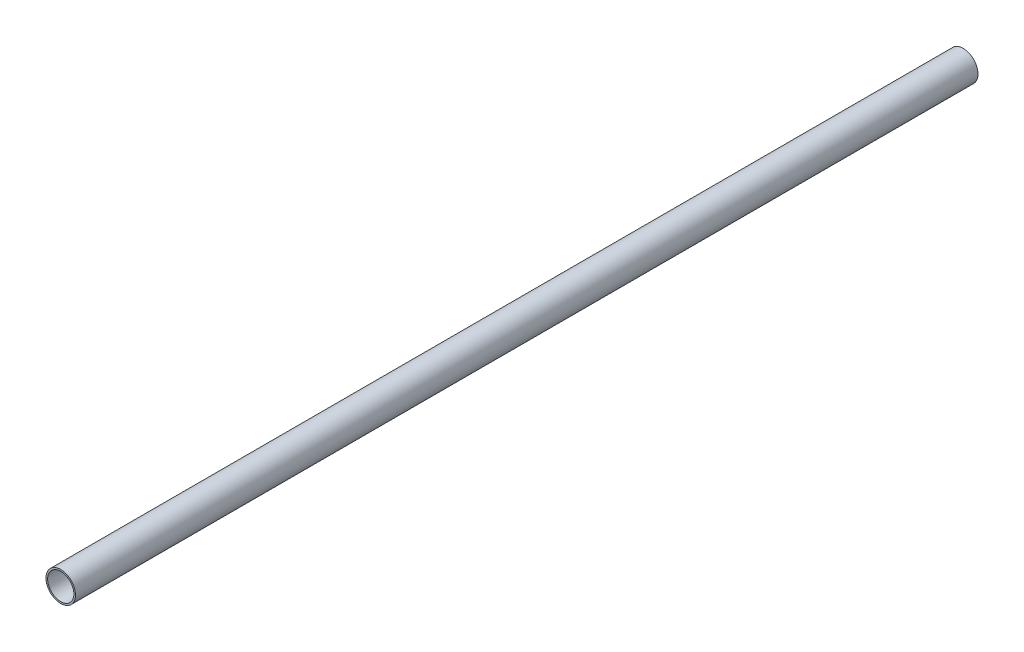
from build123d import *

# Parameters (mm, degrees)
SKETCH1_R           = 9
SKETCH1_R_2         = 8
BOSS_EXTRUDE1_DEPTH = 550


with BuildPart() as part:
    # Sketch1 → Boss-Extrude1 (new body)
    with BuildSketch(Plane.XY):
        Circle(SKETCH1_R)
        Circle(SKETCH1_R_2, mode=Mode.SUBTRACT)
    extrude(amount=BOSS_EXTRUDE1_DEPTH)


solid = part.part
